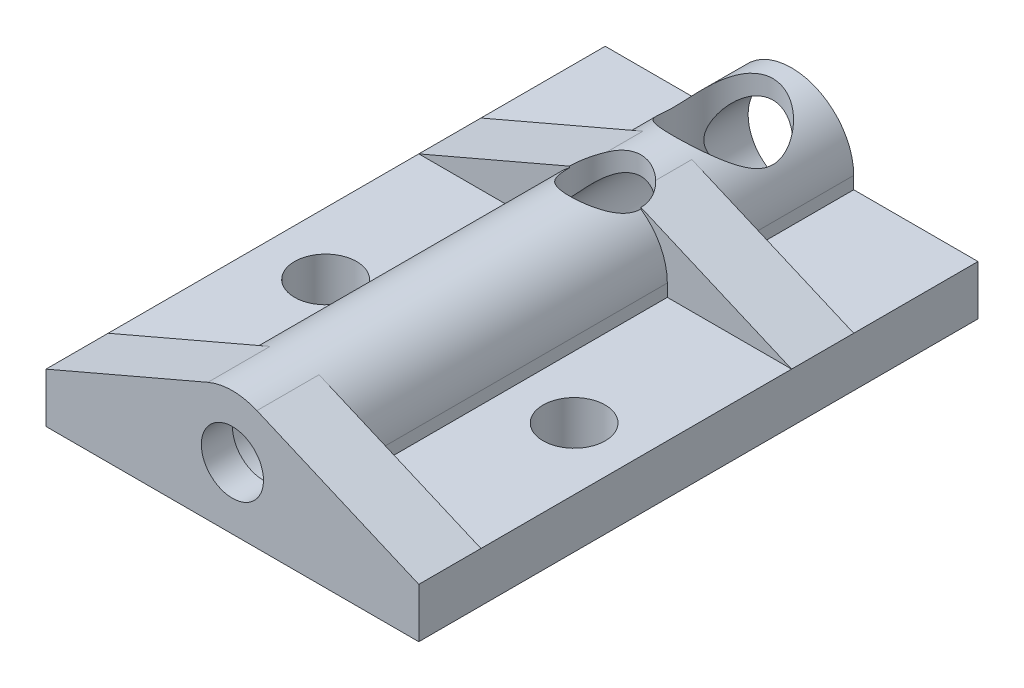
from build123d import *

# Parameters (mm, degrees)
BOSS_EXTRUDE1_DEPTH      = 17.5
BOSS_EXTRUDE1_DEPTH_BACK = 27.5
SKETCH2_W                = 45
SKETCH2_H                = 4
BOSS_EXTRUDE2_DEPTH      = 15
BOSS_EXTRUDE2_DEPTH_BACK = 15
SKETCH3_R                = 2.5
CUT_EXTRUDE1_DEPTH       = 32.721443851
CUT_EXTRUDE1_DEPTH_BACK  = 32.721443851
RIB1_REACH               = 49.697
SKETCH5_WALL_W           = 111.57136702
SKETCH5_WALL_H           = 5
MIRROR2_COPY_1_REACH     = 49.697
MIRROR2_COPY_1_SKETCH_W  = 111.57136702
MIRROR2_COPY_1_SKETCH_H  = 5
SKETCH7_R                = 2.5
CUT_EXTRUDE2_DEPTH       = 32.721443851
CUT_EXTRUDE2_DEPTH_BACK  = 32.721443851
SKETCH8_R                = 2.875
CUT_EXTRUDE3_DEPTH       = 32.721443851
CUT_EXTRUDE3_DEPTH_BACK  = 32.721443851
SKETCH9_R                = 3.5
CUT_EXTRUDE4_DEPTH       = 15
CUT_EXTRUDE4_DEPTH_BACK  = 32.721443955
SKETCH10_R               = 4
CUT_EXTRUDE5_DEPTH       = 32.721443955
CUT_EXTRUDE5_DEPTH_BACK  = 32.721443955


with BuildPart() as part:
    # Sketch1 → Boss-Extrude1 (new, two sides)
    with BuildSketch(Plane.XY) as boss_extrude1_sk:
        with BuildLine():
            Line((-5, 0), (-5, -5))
            Line((-5, -5), (5, -5))
            Line((5, -5), (5, 0))
            ThreePointArc((5, 0), (0, 5), (-5, 0))
        make_face()
    extrude(amount=BOSS_EXTRUDE1_DEPTH)
    extrude(boss_extrude1_sk.sketch, amount=-BOSS_EXTRUDE1_DEPTH_BACK)

    # Sketch2 → Boss-Extrude2 (add, two sides)
    with BuildSketch(Plane(origin=(0, 0, 0), x_dir=(0, 0, -1), z_dir=(1, 0, 0))) as boss_extrude2_sk:
        with Locations((5, -3)):
            Rectangle(SKETCH2_W, SKETCH2_H)
    extrude(amount=BOSS_EXTRUDE2_DEPTH)
    extrude(boss_extrude2_sk.sketch, amount=-BOSS_EXTRUDE2_DEPTH_BACK)

    # Sketch3 → Cut-Extrude1 (cut, two sides)
    with BuildSketch(Plane.XY) as cut_extrude1_sk:
        Circle(SKETCH3_R)
    extrude(amount=CUT_EXTRUDE1_DEPTH, mode=Mode.SUBTRACT)
    extrude(cut_extrude1_sk.sketch, amount=-CUT_EXTRUDE1_DEPTH_BACK, mode=Mode.SUBTRACT)

    # Sketch5 wall → Rib1 (add, up to next)
    with BuildSketch(Plane(origin=(8.486476183, 1.797142734, 17.5), x_dir=(0.918857093708, -0.394590472949, 0), z_dir=(0.394590472949, 0.918857093708, 0)), mode=Mode.PRIVATE) as rib1_sk1:
        with Locations((0, 2.5)):
            Rectangle(SKETCH5_WALL_W, SKETCH5_WALL_H)
    rib1_tool1 = extrude(rib1_sk1.sketch, amount=-RIB1_REACH, mode=Mode.PRIVATE) - part.part
    rib1 = rib1_tool1.solids().sort_by_distance((8.486476183, 1.797142734, 17.5))[0]
    add(rib1)

    # Mirror1: Rib1 across plane
    add(rib1.mirror(Plane.XY))

    # Mirror2: Rib1 across plane
    add(rib1.mirror(Plane(origin=(0, 0, 0), x_dir=(0, 0, 1), z_dir=(1, 0, 0))))

    # Mirror2 copy 1 sketch → Mirror2 copy 1 (add, up to next)
    with BuildSketch(Plane(origin=(-8.486476183, 1.797142734, -17.5), x_dir=(-0.918857093708, -0.394590472949, 0), z_dir=(-0.394590472949, 0.918857093708, 0)), mode=Mode.PRIVATE) as mirror2_copy_1_sk1:
        with Locations((0, 2.5)):
            Rectangle(MIRROR2_COPY_1_SKETCH_W, MIRROR2_COPY_1_SKETCH_H)
    mirror2_copy_1_tool1 = extrude(mirror2_copy_1_sk1.sketch, amount=-MIRROR2_COPY_1_REACH, mode=Mode.PRIVATE) - part.part
    add(mirror2_copy_1_tool1.solids().sort_by_distance((-8.486476183, 1.797142734, -17.5))[0])

    # Sketch7 → Cut-Extrude2 (cut, two sides)
    with BuildSketch(Plane(origin=(0, 0, 0), x_dir=(1, 0, 0), z_dir=(0, 1, 0))) as cut_extrude2_sk:
        with Locations(Location((-10, 0, 0), (0, 0, 270))):
            Circle(SKETCH7_R)
        with Locations(Location((10, 0, 0), (0, 0, 270))):
            Circle(SKETCH7_R)
    extrude(amount=CUT_EXTRUDE2_DEPTH, mode=Mode.SUBTRACT)
    extrude(cut_extrude2_sk.sketch, amount=-CUT_EXTRUDE2_DEPTH_BACK, mode=Mode.SUBTRACT)

    # Sketch8 → Cut-Extrude3 (cut, two sides)
    with BuildSketch(Plane(origin=(0, 0, 0), x_dir=(1, 0, 0), z_dir=(0, 1, 0))) as cut_extrude3_sk:
        with Locations(Location((0, 12.5, 0), (0, 0, 46.666459534))):
            Circle(SKETCH8_R)
    extrude(amount=CUT_EXTRUDE3_DEPTH, mode=Mode.SUBTRACT)
    extrude(cut_extrude3_sk.sketch, amount=-CUT_EXTRUDE3_DEPTH_BACK, mode=Mode.SUBTRACT)

    # Sketch9 → Cut-Extrude4 (cut, two sides)
    with BuildSketch(Plane.XY) as cut_extrude4_sk:
        Circle(SKETCH9_R)
    extrude(amount=CUT_EXTRUDE4_DEPTH, mode=Mode.SUBTRACT)
    extrude(cut_extrude4_sk.sketch, amount=-CUT_EXTRUDE4_DEPTH_BACK, mode=Mode.SUBTRACT)

    # Sketch10 → Cut-Extrude5 (cut, two sides)
    with BuildSketch(Plane(origin=(0, 0, 0), x_dir=(1, 0, 0), z_dir=(0, 1, 0))) as cut_extrude5_sk:
        with Locations(Location((0, 22, 0), (0, 0, 90))):
            Circle(SKETCH10_R)
    extrude(amount=CUT_EXTRUDE5_DEPTH, mode=Mode.SUBTRACT)
    extrude(cut_extrude5_sk.sketch, amount=-CUT_EXTRUDE5_DEPTH_BACK, mode=Mode.SUBTRACT)


solid = part.part
